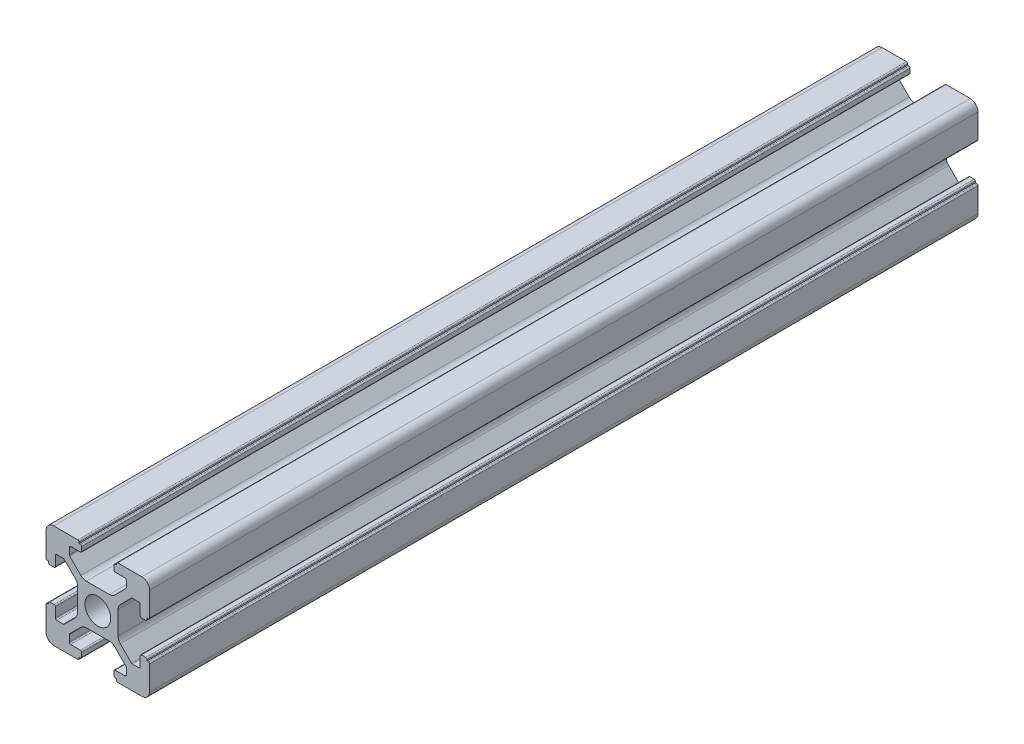
from build123d import *

# Parameters (mm, degrees)
SKETCH_1_R      = 2.5
EXTRUDE_1_DEPTH = 160


with BuildPart() as part:
    # 草图1 → 凸台-拉伸1 (new body)
    with BuildSketch(Plane.XY):
        with BuildLine():
            Line((-8.502261885, -10.002261885), (-3.85, -10.002261885))
            ThreePointArc((-3.85, -10.002261885), (-3.673223305, -9.929038581), (-3.6, -9.752261885))
            Line((-3.6, -9.752261885), (-3.6, -9.502261885))
            Line((-3.6, -9.502261885), (-3.35, -9.502261885))
            ThreePointArc((-3.35, -9.502261885), (-3.173223305, -9.429038581), (-3.1, -9.252261885))
            Line((-3.1, -9.252261885), (-3.1, -8.45))
            ThreePointArc((-3.1, -8.45), (-3.173223305, -8.273223305), (-3.35, -8.2))
            Line((-3.35, -8.2), (-5.25, -8.2))
            ThreePointArc((-5.25, -8.2), (-5.426776695, -8.126776695), (-5.5, -7.95))
            Line((-5.5, -7.95), (-5.5, -6.664213562))
            ThreePointArc((-5.5, -6.664213562), (-5.480969883, -6.568542704), (-5.426776695, -6.487436867))
            Line((-5.426776695, -6.487436867), (-3.278679656, -4.339339828))
            ThreePointArc((-3.278679656, -4.339339828), (-2.792044633, -4.014180701), (-2.218019485, -3.9))
            Line((-2.218019485, -3.9), (2.218019485, -3.9))
            ThreePointArc((2.218019485, -3.9), (2.792044633, -4.014180701), (3.278679656, -4.339339828))
            Line((3.278679656, -4.339339828), (5.426776695, -6.487436867))
            ThreePointArc((5.426776695, -6.487436867), (5.480969883, -6.568542704), (5.5, -6.664213562))
            Line((5.5, -6.664213562), (5.5, -7.95))
            ThreePointArc((5.5, -7.95), (5.426776695, -8.126776695), (5.25, -8.2))
            Line((5.25, -8.2), (3.35, -8.2))
            ThreePointArc((3.35, -8.2), (3.173223305, -8.273223305), (3.1, -8.45))
            Line((3.1, -8.45), (3.1, -9.252261885))
            ThreePointArc((3.1, -9.252261885), (3.173223305, -9.429038581), (3.35, -9.502261885))
            Line((3.35, -9.502261885), (3.6, -9.502261885))
            Line((3.6, -9.502261885), (3.6, -9.752261885))
            ThreePointArc((3.6, -9.752261885), (3.673223305, -9.929038581), (3.85, -10.002261885))
            Line((3.85, -10.002261885), (8.502261885, -10.002261885))
            ThreePointArc((8.502261885, -10.002261885), (9.562922057, -9.562922057), (10.002261885, -8.502261885))
            Line((10.002261885, -8.502261885), (10.002261885, -3.85))
            ThreePointArc((10.002261885, -3.85), (9.929038581, -3.673223305), (9.752261885, -3.6))
            Line((9.752261885, -3.6), (9.502261885, -3.6))
            Line((9.502261885, -3.6), (9.502261885, -3.35))
            ThreePointArc((9.502261885, -3.35), (9.429038581, -3.173223305), (9.252261885, -3.1))
            Line((9.252261885, -3.1), (8.45, -3.1))
            ThreePointArc((8.45, -3.1), (8.273223305, -3.173223305), (8.2, -3.35))
            Line((8.2, -3.35), (8.2, -5.25))
            ThreePointArc((8.2, -5.25), (8.126776695, -5.426776695), (7.95, -5.5))
            Line((7.95, -5.5), (6.664213562, -5.5))
            ThreePointArc((6.664213562, -5.5), (6.568542704, -5.480969883), (6.487436867, -5.426776695))
            Line((6.487436867, -5.426776695), (4.339339828, -3.278679656))
            ThreePointArc((4.339339828, -3.278679656), (4.014180701, -2.792044633), (3.9, -2.218019485))
            Line((3.9, -2.218019485), (3.9, 2.218019485))
            ThreePointArc((3.9, 2.218019485), (4.014180701, 2.792044633), (4.339339828, 3.278679656))
            Line((4.339339828, 3.278679656), (6.487436867, 5.426776695))
            ThreePointArc((6.487436867, 5.426776695), (6.568542704, 5.480969883), (6.664213562, 5.5))
            Line((6.664213562, 5.5), (7.95, 5.5))
            ThreePointArc((7.95, 5.5), (8.126776695, 5.426776695), (8.2, 5.25))
            Line((8.2, 5.25), (8.2, 3.35))
            ThreePointArc((8.2, 3.35), (8.273223305, 3.173223305), (8.45, 3.1))
            Line((8.45, 3.1), (9.252261885, 3.1))
            ThreePointArc((9.252261885, 3.1), (9.429038581, 3.173223305), (9.502261885, 3.35))
            Line((9.502261885, 3.35), (9.502261885, 3.6))
            Line((9.502261885, 3.6), (9.752261885, 3.6))
            ThreePointArc((9.752261885, 3.6), (9.929038581, 3.673223305), (10.002261885, 3.85))
            Line((10.002261885, 3.85), (10.002261885, 8.502261885))
            ThreePointArc((10.002261885, 8.502261885), (9.562922057, 9.562922057), (8.502261885, 10.002261885))
            Line((8.502261885, 10.002261885), (3.85, 10.002261885))
            ThreePointArc((3.85, 10.002261885), (3.673223305, 9.929038581), (3.6, 9.752261885))
            Line((3.6, 9.752261885), (3.6, 9.502261885))
            Line((3.6, 9.502261885), (3.35, 9.502261885))
            ThreePointArc((3.35, 9.502261885), (3.173223305, 9.429038581), (3.1, 9.252261885))
            Line((3.1, 9.252261885), (3.1, 8.45))
            ThreePointArc((3.1, 8.45), (3.173223305, 8.273223305), (3.35, 8.2))
            Line((3.35, 8.2), (5.25, 8.2))
            ThreePointArc((5.25, 8.2), (5.426776695, 8.126776695), (5.5, 7.95))
            Line((5.5, 7.95), (5.5, 6.664213562))
            ThreePointArc((5.5, 6.664213562), (5.480969883, 6.568542704), (5.426776695, 6.487436867))
            Line((5.426776695, 6.487436867), (3.278679656, 4.339339828))
            ThreePointArc((3.278679656, 4.339339828), (2.792044633, 4.014180701), (2.218019485, 3.9))
            Line((2.218019485, 3.9), (-2.218019485, 3.9))
            ThreePointArc((-2.218019485, 3.9), (-2.792044633, 4.014180701), (-3.278679656, 4.339339828))
            Line((-3.278679656, 4.339339828), (-5.426776695, 6.487436867))
            ThreePointArc((-5.426776695, 6.487436867), (-5.480969883, 6.568542704), (-5.5, 6.664213562))
            Line((-5.5, 6.664213562), (-5.5, 7.95))
            ThreePointArc((-5.5, 7.95), (-5.426776695, 8.126776695), (-5.25, 8.2))
            Line((-5.25, 8.2), (-3.35, 8.2))
            ThreePointArc((-3.35, 8.2), (-3.173223305, 8.273223305), (-3.1, 8.45))
            Line((-3.1, 8.45), (-3.1, 9.252261885))
            ThreePointArc((-3.1, 9.252261885), (-3.173223305, 9.429038581), (-3.35, 9.502261885))
            Line((-3.35, 9.502261885), (-3.6, 9.502261885))
            Line((-3.6, 9.502261885), (-3.6, 9.752261885))
            ThreePointArc((-3.6, 9.752261885), (-3.673223305, 9.929038581), (-3.85, 10.002261885))
            Line((-3.85, 10.002261885), (-8.502261885, 10.002261885))
            ThreePointArc((-8.502261885, 10.002261885), (-9.562922057, 9.562922057), (-10.002261885, 8.502261885))
            Line((-10.002261885, 8.502261885), (-10.002261885, 3.85))
            ThreePointArc((-10.002261885, 3.85), (-9.929038581, 3.673223305), (-9.752261885, 3.6))
            Line((-9.752261885, 3.6), (-9.502261885, 3.6))
            Line((-9.502261885, 3.6), (-9.502261885, 3.35))
            ThreePointArc((-9.502261885, 3.35), (-9.429038581, 3.173223305), (-9.252261885, 3.1))
            Line((-9.252261885, 3.1), (-8.45, 3.1))
            ThreePointArc((-8.45, 3.1), (-8.273223305, 3.173223305), (-8.2, 3.35))
            Line((-8.2, 3.35), (-8.2, 5.25))
            ThreePointArc((-8.2, 5.25), (-8.126776695, 5.426776695), (-7.95, 5.5))
            Line((-7.95, 5.5), (-6.664213562, 5.5))
            ThreePointArc((-6.664213562, 5.5), (-6.568542704, 5.480969883), (-6.487436867, 5.426776695))
            Line((-6.487436867, 5.426776695), (-4.339339828, 3.278679656))
            ThreePointArc((-4.339339828, 3.278679656), (-4.014180701, 2.792044633), (-3.9, 2.218019485))
            Line((-3.9, 2.218019485), (-3.9, -2.218019485))
            ThreePointArc((-3.9, -2.218019485), (-4.014180701, -2.792044633), (-4.339339828, -3.278679656))
            Line((-4.339339828, -3.278679656), (-6.487436867, -5.426776695))
            ThreePointArc((-6.487436867, -5.426776695), (-6.568542704, -5.480969883), (-6.664213562, -5.5))
            Line((-6.664213562, -5.5), (-7.95, -5.5))
            ThreePointArc((-7.95, -5.5), (-8.126776695, -5.426776695), (-8.2, -5.25))
            Line((-8.2, -5.25), (-8.2, -3.35))
            ThreePointArc((-8.2, -3.35), (-8.273223305, -3.173223305), (-8.45, -3.1))
            Line((-8.45, -3.1), (-9.252261885, -3.1))
            ThreePointArc((-9.252261885, -3.1), (-9.429038581, -3.173223305), (-9.502261885, -3.35))
            Line((-9.502261885, -3.35), (-9.502261885, -3.6))
            Line((-9.502261885, -3.6), (-9.752261885, -3.6))
            ThreePointArc((-9.752261885, -3.6), (-9.929038581, -3.673223305), (-10.002261885, -3.85))
            Line((-10.002261885, -3.85), (-10.002261885, -8.502261885))
            ThreePointArc((-10.002261885, -8.502261885), (-9.562922057, -9.562922057), (-8.502261885, -10.002261885))
        make_face()
        Circle(SKETCH_1_R, mode=Mode.SUBTRACT)
    extrude(amount=EXTRUDE_1_DEPTH)


solid = part.part
